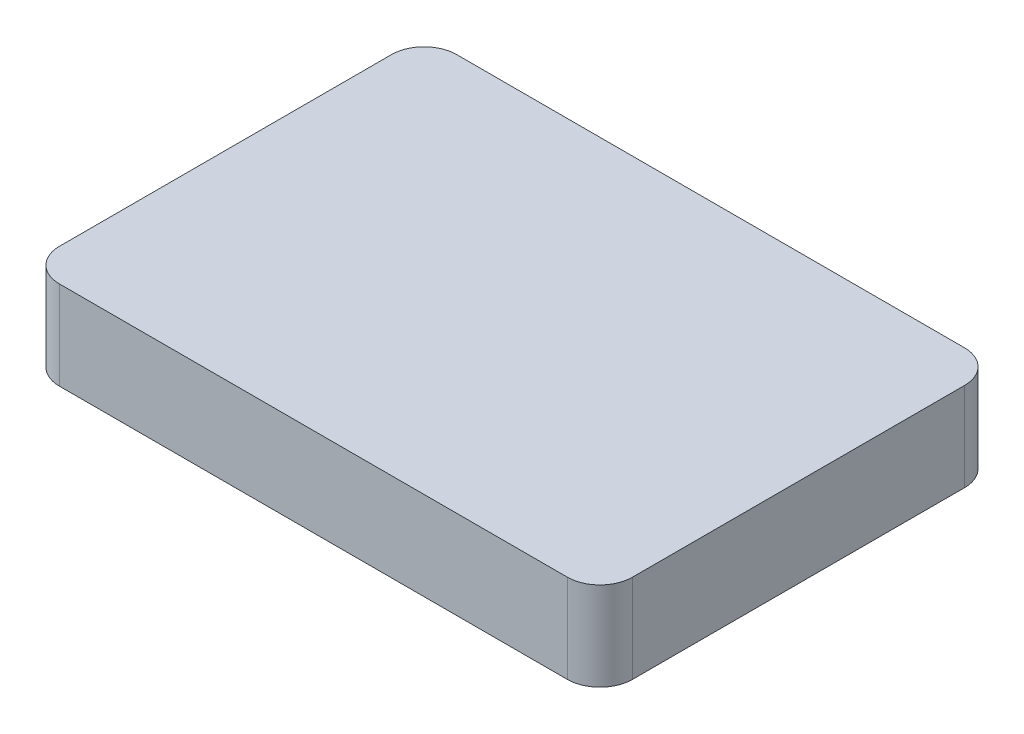
from build123d import *

# Parameters (mm, degrees)
SKETCH1_W           = 44
SKETCH1_H           = 30.5
BOSS_EXTRUDE1_DEPTH = 3.4
FILLET1_R           = 2.5


with BuildPart() as part:
    # Sketch1 → Boss-Extrude1 (new body, symmetric)
    with BuildSketch(Plane(origin=(0, 0, 0), x_dir=(1, 0, 0), z_dir=(0, 1, 0))):
        Rectangle(SKETCH1_W, SKETCH1_H)
    extrude(amount=BOSS_EXTRUDE1_DEPTH, both=True)

    # Fillet1
    fillet1_edges = [part.edges().sort_by_distance(p)[0] for p in [
        (22, 0, 15.25),
        (-22, 0, 15.25),
        (-22, 0, -15.25),
        (22, 0, -15.25),
    ]]
    fillet(fillet1_edges, radius=FILLET1_R)


solid = part.part
